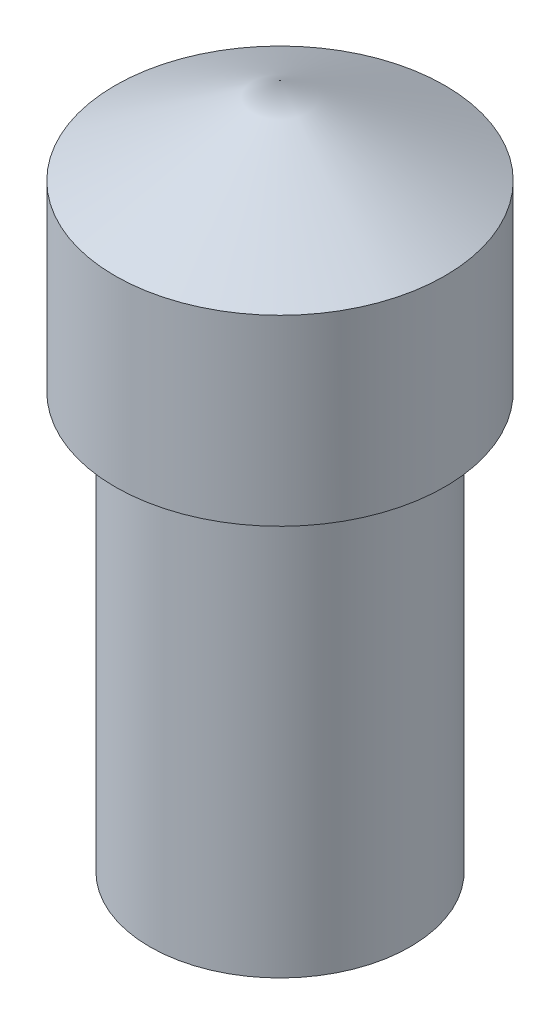
from build123d import *


with BuildPart() as part:
    # Sketch2 → Revolve1 (revolve)
    with BuildSketch(Plane.XY):
        Polygon((0, 0), (0.75, 0), (0.75, 2.394736842), (0.95, 2.394736842), (0.95, 3.447368421), (0, 3.947368421), align=None)
    revolve(axis=Axis((0, 3.947368421, 0), (0, -1, 0)))


solid = part.part
